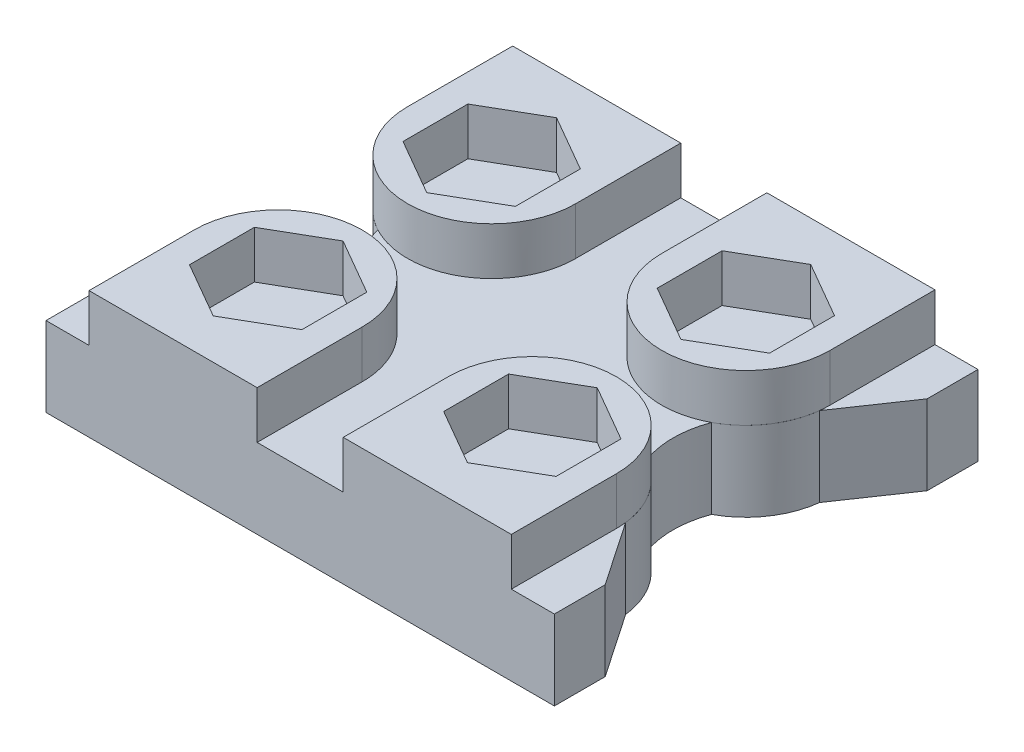
from build123d import *

# Parameters (mm, degrees)
EXTRUDE2_DEPTH = 4.7
EXTRUDE3_DEPTH = 2.8


with BuildPart() as part:
    # Sketch1 → Extrude2 (new body)
    with BuildSketch(Plane(origin=(0, 0, 0), x_dir=(1, 0, 0), z_dir=(0, 1, 0))):
        with BuildLine():
            Line((0, 0), (30, 0))
            Line((30, 0), (30, 3))
            Line((30, 3), (27.428441876, 6.776441992))
            ThreePointArc((27.428441876, 6.776441992), (26.604060948, 8.988997747), (24.850416315, 10.570053529))
            ThreePointArc((24.850416315, 10.570053529), (24.500644991, 12.5), (24.850416315, 14.429946471))
            ThreePointArc((24.850416315, 14.429946471), (26.604060948, 16.011002253), (27.428441876, 18.223558008))
            Line((27.428441876, 18.223558008), (30, 22))
            Line((30, 22), (30, 25))
            Line((30, 25), (0, 25))
            Line((0, 25), (0, 22))
            Line((0, 22), (2.571558124, 18.223558008))
            ThreePointArc((2.571558124, 18.223558008), (3.395939052, 16.011002253), (5.149583685, 14.429946471))
            ThreePointArc((5.149583685, 14.429946471), (5.499355009, 12.5), (5.149583685, 10.570053529))
            ThreePointArc((5.149583685, 10.570053529), (3.395939052, 8.988997747), (2.571558124, 6.776441992))
            Line((2.571558124, 6.776441992), (0, 3))
            Line((0, 3), (0, 0))
        make_face()
    extrude(amount=EXTRUDE2_DEPTH)

    # Sketch3 → Extrude3 (add)
    with BuildSketch(Plane(origin=(0, 4.7, 0), x_dir=(1, 0, 0), z_dir=(0, 1, 0))):
        with BuildLine():
            Line((2.54, 6.2), (2.54, 0))
            Line((2.54, 0), (12.46, 0))
            Line((12.46, 0), (12.46, 6.2))
            ThreePointArc((12.46, 6.2), (7.5, 11.16), (2.54, 6.2))
        make_face()
        Polygon((7.5, 10.03), (4.183122704, 8.115), (4.183122704, 4.285), (7.5, 2.37), (10.816877296, 4.285), (10.816877296, 8.115), align=None, mode=Mode.SUBTRACT)
        with BuildLine():
            Line((2.54, 18.8), (2.54, 25))
            Line((2.54, 25), (12.46, 25))
            Line((12.46, 25), (12.46, 18.8))
            ThreePointArc((12.46, 18.8), (7.5, 13.84), (2.54, 18.8))
        make_face()
        Polygon((7.5, 22.63), (4.183122704, 20.715), (4.183122704, 16.885), (7.5, 14.97), (10.816877296, 16.885), (10.816877296, 20.715), align=None, mode=Mode.SUBTRACT)
        with BuildLine():
            Line((27.46, 0), (17.54, 0))
            Line((17.54, 0), (17.54, 6.2))
            ThreePointArc((17.54, 6.2), (22.5, 11.16), (27.46, 6.2))
            Line((27.46, 6.2), (27.46, 0))
        make_face()
        Polygon((19.183122704, 4.285), (19.183122704, 8.115), (22.5, 10.03), (25.816877296, 8.115), (25.816877296, 4.285), (22.5, 2.37), align=None, mode=Mode.SUBTRACT)
        with BuildLine():
            Line((17.54, 18.8), (17.54, 25))
            Line((17.54, 25), (27.46, 25))
            Line((27.46, 25), (27.46, 18.8))
            ThreePointArc((27.46, 18.8), (22.5, 13.84), (17.54, 18.8))
        make_face()
        Polygon((25.816877296, 16.885), (22.5, 14.97), (19.183122704, 16.885), (19.183122704, 20.715), (22.5, 22.63), (25.816877296, 20.715), align=None, mode=Mode.SUBTRACT)
    extrude(amount=EXTRUDE3_DEPTH)


solid = part.part
